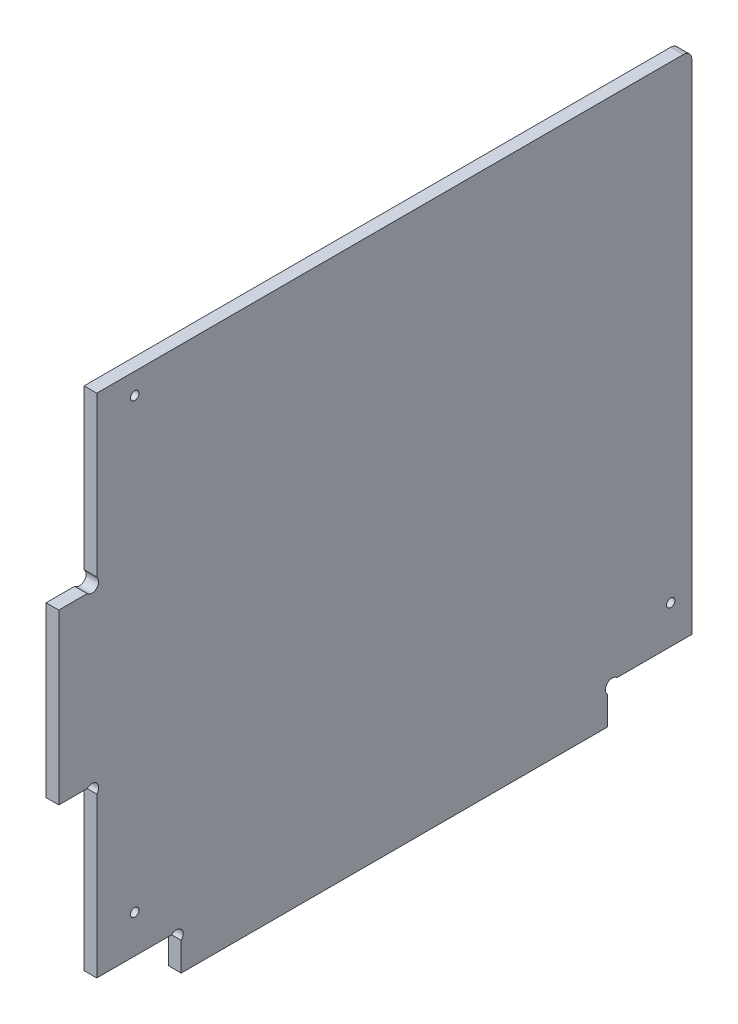
from build123d import *

# Parameters (mm, degrees)
EXTRUSION1_DEPTH        = 3
ESQUISSE2_R             = 1
ENL_V_MAT_EXTRU_1_DEPTH = 4
CONG_1_R                = 2


with BuildPart() as part:
    # Esquisse1 → Extrusion1 (new body)
    with BuildSketch(Plane(origin=(0, 0, 0), x_dir=(0, 0, -1), z_dir=(1, 0, 0))):
        with BuildLine():
            Line((130, 6.7372583), (130, 0))
            Line((130, 0), (29, 0))
            Line((29, 0), (29, 6.7372583))
            ThreePointArc((29, 6.7372583), (29, 9), (26.7372583, 9))
            Line((26.7372583, 9), (9, 9))
            Line((9, 9), (9, 46.7372583))
            ThreePointArc((9, 46.7372583), (9, 49), (6.7372583, 49))
            Line((6.7372583, 49), (0, 49))
            Line((0, 49), (0, 89))
            Line((0, 89), (6.7372583, 89))
            ThreePointArc((6.7372583, 89), (9, 89), (9, 91.2627417))
            Line((9, 91.2627417), (9, 129))
            Line((9, 129), (150, 129))
            Line((150, 129), (150, 9))
            Line((150, 9), (132.2627417, 9))
            ThreePointArc((132.2627417, 9), (130, 9), (130, 6.7372583))
        make_face()
    extrude(amount=EXTRUSION1_DEPTH)

    # Esquisse2 → Enlèv. mat.-Extru.1 (cut, through all)
    with BuildSketch(Plane(origin=(3, 0, 0), x_dir=(0, 0, -1), z_dir=(1, 0, 0))):
        with Locations((18, 124)):
            Circle(ESQUISSE2_R)
        with Locations((18, 18)):
            Circle(ESQUISSE2_R)
        with Locations((145, 18)):
            Circle(ESQUISSE2_R)
    extrude(amount=-ENL_V_MAT_EXTRU_1_DEPTH, mode=Mode.SUBTRACT)

    # Congé1
    cong_1_edges = [part.edges().sort_by_distance(p)[0] for p in [
        (1.5, 129, -150),
    ]]
    fillet(cong_1_edges, radius=CONG_1_R)


solid = part.part
